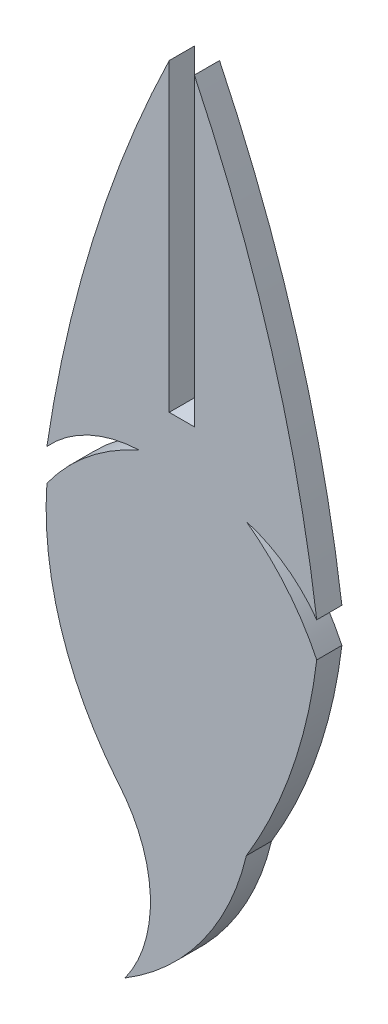
from build123d import *

# Parameters (mm, degrees)
BOSS_EXTRUDE1_DEPTH = 1.524


with BuildPart() as part:
    # Sketch1 → Boss-Extrude1 (new body)
    with BuildSketch(Plane.XY):
        with BuildLine():
            Line((-1.524, -34.676201819), (0, -34.676201819))
            Line((0, -34.676201819), (0, -16.207111739))
            ThreePointArc((0, -16.207111739), (4.689743942, -28.359934479), (7.416031026, -41.097758371))
            ThreePointArc((7.416031026, -41.097758371), (5.538015882, -39.224408686), (3.150525994, -38.068436386))
            ThreePointArc((3.150525994, -38.068436386), (5.602261388, -40.371046875), (7.416031026, -43.203583054))
            ThreePointArc((7.416031026, -43.203583054), (5.940545724, -49.63331575), (3.150525994, -55.611133859))
            ThreePointArc((3.150525994, -55.611133859), (0.484501077, -61.400215867), (-4.208602653, -65.7125165))
            ThreePointArc((-4.208602653, -65.7125165), (-2.673725859, -60.580284143), (-4.674525994, -55.611133859))
            ThreePointArc((-4.674525994, -55.611133859), (-8.093459753, -49.265692558), (-8.940031026, -42.107686522))
            ThreePointArc((-8.940031026, -42.107686522), (-6.444201433, -39.460606713), (-3.337442556, -37.567396171))
            ThreePointArc((-3.337442556, -37.567396171), (-6.400806633, -38.308208766), (-8.940031026, -40.1751159))
            ThreePointArc((-8.940031026, -40.1751159), (-6.144837349, -27.908674155), (-1.524, -16.207111739))
            Line((-1.524, -16.207111739), (-1.524, -34.676201819))
        make_face()
    extrude(amount=BOSS_EXTRUDE1_DEPTH)


solid = part.part
